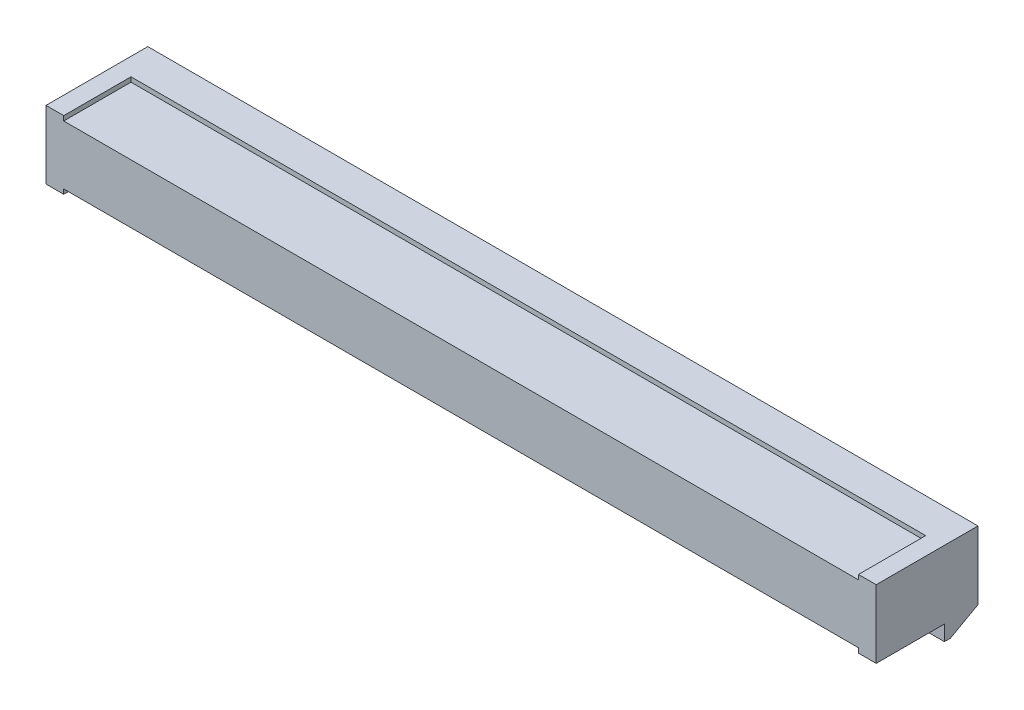
from build123d import *

# Parameters (mm, degrees)
SKETCH1_W           = 88.9
SKETCH1_H           = 10.9
BOSS_EXTRUDE1_DEPTH = 3.65
SKETCH2_W           = 85.1
SKETCH2_H           = 7.2
CUT_EXTRUDE1_DEPTH  = 0.5
SKETCH3_W           = 11.7
SKETCH3_H           = 0.85
SKETCH3_W_2         = 71.7
CUT_EXTRUDE2_DEPTH  = 7.82
CHAMFER1_SIZE       = 0.3
SKETCH4_W           = 1.2
SKETCH4_H           = 1.2
CUT_EXTRUDE3_DEPTH  = 7.82
SKETCH5_W           = 0.5
SKETCH5_H           = 1.37
CUT_EXTRUDE4_DEPTH  = 7.82
LPATTERN1_COUNT     = 84
LPATTERN1_PITCH     = 1
BOSS_EXTRUDE2_DEPTH = 88.9
SKETCH7_W           = 1.27
SKETCH7_H           = 1.637455432
CUT_EXTRUDE5_DEPTH  = 11.9
LPATTERN3_COUNT     = 17
LPATTERN3_PITCH     = 5


with BuildPart() as part:
    # Sketch1 → Boss-Extrude1 (new body)
    with BuildSketch(Plane(origin=(0, 0, 0), x_dir=(1, 0, 0), z_dir=(0, 1, 0))):
        Rectangle(SKETCH1_W, SKETCH1_H)
    extrude(amount=BOSS_EXTRUDE1_DEPTH)

    # Sketch2 → Cut-Extrude1 (cut)
    with BuildSketch(Plane(origin=(0, 3.65, 0), x_dir=(1, 0, 0), z_dir=(0, 1, 0))):
        with Locations((0, -1.85)):
            Rectangle(SKETCH2_W, SKETCH2_H)
    extrude(amount=-CUT_EXTRUDE1_DEPTH, mode=Mode.SUBTRACT)

    # Sketch3 → Cut-Extrude2 (cut)
    with BuildSketch(Plane(origin=(0, 0, -5.45), x_dir=(-1, 0, 0), z_dir=(0, 0, -1))):
        with Locations((-36.7, 0.425)):
            Rectangle(SKETCH3_W, SKETCH3_H)
        with Locations((6.7, 0.425)):
            Rectangle(SKETCH3_W_2, SKETCH3_H)
    extrude(amount=-CUT_EXTRUDE2_DEPTH, mode=Mode.SUBTRACT)

    # Chamfer1
    chamfer1_edges = [part.edges().sort_by_distance(p)[0] for p in [
        (30.85, 0.425, -5.45),
        (29.15, 0.425, -5.45),
    ]]
    chamfer(chamfer1_edges, length=CHAMFER1_SIZE)

    # Sketch4 → Cut-Extrude3 (cut)
    with BuildSketch(Plane(origin=(0, 0, -5.45), x_dir=(-1, 0, 0), z_dir=(0, 0, -1))):
        with Locations((-43.01, 2.28)):
            Rectangle(SKETCH4_W, SKETCH4_H)
        with Locations((-30, 2.28)):
            Rectangle(SKETCH4_W, SKETCH4_H)
        with Locations((43.01, 2.28)):
            Rectangle(SKETCH4_W, SKETCH4_H)
    extrude(amount=-CUT_EXTRUDE3_DEPTH, mode=Mode.SUBTRACT)

    # Sketch5 → Cut-Extrude4 (cut)
    with BuildSketch(Plane(origin=(0, 0, -5.45), x_dir=(-1, 0, 0), z_dir=(0, 0, -1))):
        with Locations((-41.66, 2.225)):
            Rectangle(SKETCH5_W, SKETCH5_H)
    cut_extrude4 = extrude(amount=-CUT_EXTRUDE4_DEPTH, mode=Mode.SUBTRACT)

    # LPattern1: Cut-Extrude4 ×84, 2 skipped
    with Locations(*[(-i * LPATTERN1_PITCH, 0, 0) for i in range(1, LPATTERN1_COUNT) if i not in (11, 12)]):
        add(cut_extrude4, mode=Mode.SUBTRACT)

    # Mirror1: part across plane


with BuildPart() as part_1:
    add(part.part)
    add(part.part.mirror(Plane(origin=(0, 0, 0), x_dir=(0, 0, 1), z_dir=(0, -1, 0))))

    # Sketch6 → Boss-Extrude2 (add)
    with BuildSketch(Plane(origin=(44.45, 0, 0), x_dir=(0, 0, -1), z_dir=(1, 0, 0))):
        Polygon((5.45, -3.65), (2.502580222, -5.287455432), (1.85, -5.287455432), (1.85, -3.65), align=None)
    extrude(amount=-BOSS_EXTRUDE2_DEPTH)

    # Sketch7 → Cut-Extrude5 (cut, through all)
    with BuildSketch(Plane(origin=(0, 0, -5.45), x_dir=(-1, 0, 0), z_dir=(0, 0, -1))):
        with Locations((-39.815, -4.468727716)):
            Rectangle(SKETCH7_W, SKETCH7_H)
    cut_extrude5 = extrude(amount=-CUT_EXTRUDE5_DEPTH, mode=Mode.SUBTRACT)

    # LPattern3: Cut-Extrude5 ×17
    with Locations(*[(-i * LPATTERN3_PITCH, 0, 0) for i in range(1, LPATTERN3_COUNT)]):
        add(cut_extrude5, mode=Mode.SUBTRACT)


solid = part_1.part
